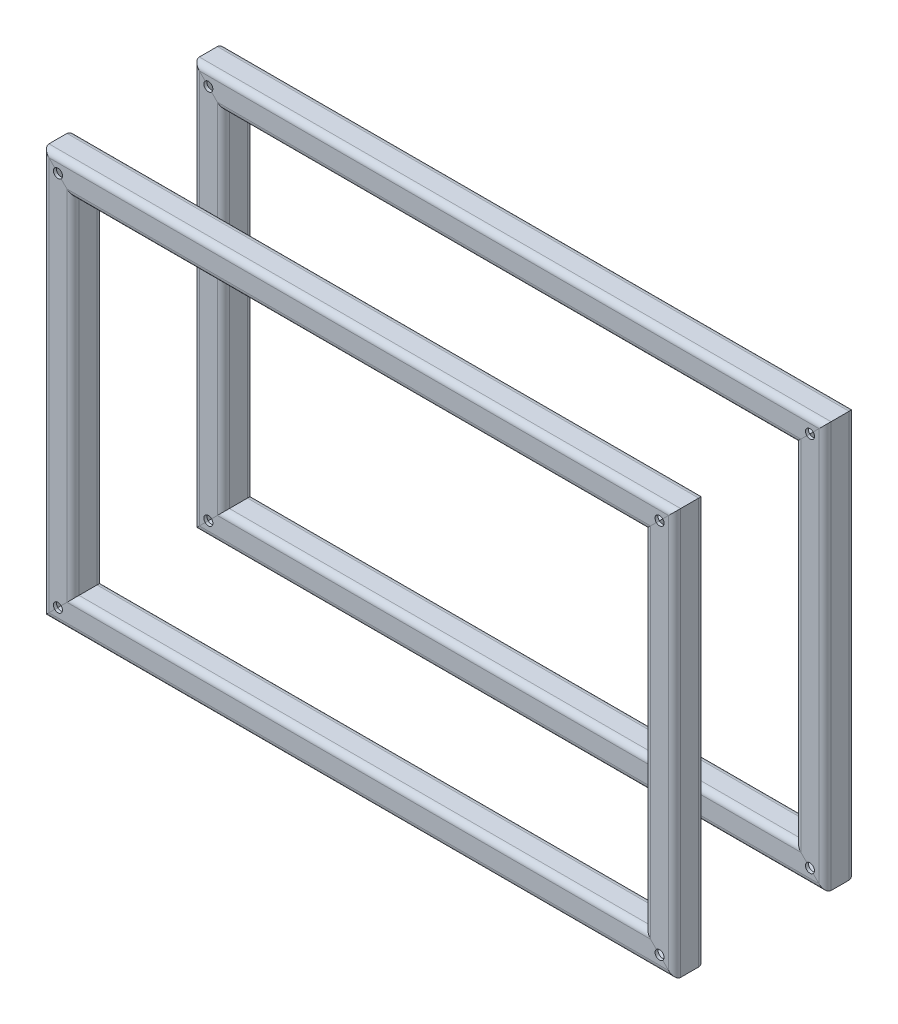
from build123d import *

# Parameters (mm, degrees)
KARE_T_P_20_X_20_X_2_1_DEPTH      = 415.142135624
KARE_T_P_20_X_20_X_2_1_DEPTH_BACK = 15.142135624
KARE_T_P_20_X_20_X_2_1_2_DEPTH    = 280.284271247
KARE_T_P_20_X_20_X_2_1_3_DEPTH    = 430.284271247
KARE_T_P_20_X_20_X_2_1_4_DEPTH    = 280.284271247
IZIM1_R                           = 3
KES_EKSTR_ZYON1_DEPTH             = 277.992779689
KES_EKSTR_ZYON1_DEPTH_BACK        = 277.992779689


with BuildPart() as part:
    # Sketch1 → Kare tüp 20 X 20 X 2(1) (new, two sides)
    with BuildSketch(Plane(origin=(-200, 125, 0), x_dir=(0, 0, -1), z_dir=(1, 0, 0))) as kare_t_p_20_x_20_x_2_1_sk:
        with BuildLine():
            Line((-6, -10), (6, -10))
            ThreePointArc((6, -10), (8.828427125, -8.828427125), (10, -6))
            Line((10, -6), (10, 6))
            ThreePointArc((10, 6), (8.828427125, 8.828427125), (6, 10))
            Line((6, 10), (-6, 10))
            ThreePointArc((-6, 10), (-8.828427125, 8.828427125), (-10, 6))
            Line((-10, 6), (-10, -6))
            ThreePointArc((-10, -6), (-8.828427125, -8.828427125), (-6, -10))
        make_face()
        with BuildLine():
            Line((-6, -8), (6, -8))
            ThreePointArc((6, -8), (7.414213562, -7.414213562), (8, -6))
            Line((8, -6), (8, 6))
            ThreePointArc((8, 6), (7.414213562, 7.414213562), (6, 8))
            Line((6, 8), (-6, 8))
            ThreePointArc((-6, 8), (-7.414213562, 7.414213562), (-8, 6))
            Line((-8, 6), (-8, -6))
            ThreePointArc((-8, -6), (-7.414213562, -7.414213562), (-6, -8))
        make_face(mode=Mode.SUBTRACT)
    extrude(amount=KARE_T_P_20_X_20_X_2_1_DEPTH)
    extrude(kare_t_p_20_x_20_x_2_1_sk.sketch, amount=-KARE_T_P_20_X_20_X_2_1_DEPTH_BACK)

    # Kare tüp 20 X 20 X 2(1) mitre 1
    split(bisect_by=Plane(origin=(-200, 125, 0), x_dir=(-0.707106781, 0.707106781, 0), z_dir=(0.707106781, 0.707106781, 0)), keep=Keep.TOP)

    # Kare tüp 20 X 20 X 2(1) mitre 2
    split(bisect_by=Plane(origin=(200, 125, 0), x_dir=(-0.707106781, -0.707106781, 0), z_dir=(-0.707106781, 0.707106781, 0)), keep=Keep.TOP)


with BuildPart() as body_2:
    # Sketch1 on segment 2 (carried to segment 2) → Kare t_p 20 X 20 X 2_1 2 (new body)
    with BuildSketch(Plane(origin=(200, 140.142135624, 0), x_dir=(0, 0, -1), z_dir=(0, -1, 0))):
        with BuildLine():
            Line((-6, -10), (6, -10))
            ThreePointArc((6, -10), (8.828427125, -8.828427125), (10, -6))
            Line((10, -6), (10, 6))
            ThreePointArc((10, 6), (8.828427125, 8.828427125), (6, 10))
            Line((6, 10), (-6, 10))
            ThreePointArc((-6, 10), (-8.828427125, 8.828427125), (-10, 6))
            Line((-10, 6), (-10, -6))
            ThreePointArc((-10, -6), (-8.828427125, -8.828427125), (-6, -10))
        make_face()
        with BuildLine():
            Line((-6, -8), (6, -8))
            ThreePointArc((6, -8), (7.414213562, -7.414213562), (8, -6))
            Line((8, -6), (8, 6))
            ThreePointArc((8, 6), (7.414213562, 7.414213562), (6, 8))
            Line((6, 8), (-6, 8))
            ThreePointArc((-6, 8), (-7.414213562, 7.414213562), (-8, 6))
            Line((-8, 6), (-8, -6))
            ThreePointArc((-8, -6), (-7.414213562, -7.414213562), (-6, -8))
        make_face(mode=Mode.SUBTRACT)
    extrude(amount=KARE_T_P_20_X_20_X_2_1_2_DEPTH)

    # Kare t_p 20 X 20 X 2_1 2 mitre 1
    split(bisect_by=Plane(origin=(200, 125, 0), x_dir=(0.707106781, 0.707106781, 0), z_dir=(0.707106781, -0.707106781, 0)), keep=Keep.TOP)

    # Kare t_p 20 X 20 X 2_1 2 mitre 2
    split(bisect_by=Plane(origin=(200, -125, 0), x_dir=(-0.707106781, 0.707106781, 0), z_dir=(0.707106781, 0.707106781, 0)), keep=Keep.TOP)


with BuildPart() as body_3:
    # Sketch1 on segment 3 (carried to segment 3) → Kare t_p 20 X 20 X 2_1 3 (new body)
    with BuildSketch(Plane(origin=(215.142135624, -125, 0), x_dir=(0, 0, -1), z_dir=(-1, 0, 0))):
        with BuildLine():
            Line((-6, -10), (6, -10))
            ThreePointArc((6, -10), (8.828427125, -8.828427125), (10, -6))
            Line((10, -6), (10, 6))
            ThreePointArc((10, 6), (8.828427125, 8.828427125), (6, 10))
            Line((6, 10), (-6, 10))
            ThreePointArc((-6, 10), (-8.828427125, 8.828427125), (-10, 6))
            Line((-10, 6), (-10, -6))
            ThreePointArc((-10, -6), (-8.828427125, -8.828427125), (-6, -10))
        make_face()
        with BuildLine():
            Line((-6, -8), (6, -8))
            ThreePointArc((6, -8), (7.414213562, -7.414213562), (8, -6))
            Line((8, -6), (8, 6))
            ThreePointArc((8, 6), (7.414213562, 7.414213562), (6, 8))
            Line((6, 8), (-6, 8))
            ThreePointArc((-6, 8), (-7.414213562, 7.414213562), (-8, 6))
            Line((-8, 6), (-8, -6))
            ThreePointArc((-8, -6), (-7.414213562, -7.414213562), (-6, -8))
        make_face(mode=Mode.SUBTRACT)
    extrude(amount=KARE_T_P_20_X_20_X_2_1_3_DEPTH)

    # Kare t_p 20 X 20 X 2_1 3 mitre 1
    split(bisect_by=Plane(origin=(-200, -125, 0), x_dir=(0.707106781, 0.707106781, 0), z_dir=(0.707106781, -0.707106781, 0)), keep=Keep.TOP)

    # Kare t_p 20 X 20 X 2_1 3 mitre 2
    split(bisect_by=Plane(origin=(200, -125, 0), x_dir=(0.707106781, -0.707106781, 0), z_dir=(-0.707106781, -0.707106781, 0)), keep=Keep.TOP)


with BuildPart() as body_4:
    # Sketch1 on segment 4 (carried to segment 4) → Kare t_p 20 X 20 X 2_1 4 (new body)
    with BuildSketch(Plane(origin=(-200, -140.142135624, 0), x_dir=(0, 0, -1), z_dir=(0, 1, 0))):
        with BuildLine():
            Line((-6, -10), (6, -10))
            ThreePointArc((6, -10), (8.828427125, -8.828427125), (10, -6))
            Line((10, -6), (10, 6))
            ThreePointArc((10, 6), (8.828427125, 8.828427125), (6, 10))
            Line((6, 10), (-6, 10))
            ThreePointArc((-6, 10), (-8.828427125, 8.828427125), (-10, 6))
            Line((-10, 6), (-10, -6))
            ThreePointArc((-10, -6), (-8.828427125, -8.828427125), (-6, -10))
        make_face()
        with BuildLine():
            Line((-6, -8), (6, -8))
            ThreePointArc((6, -8), (7.414213562, -7.414213562), (8, -6))
            Line((8, -6), (8, 6))
            ThreePointArc((8, 6), (7.414213562, 7.414213562), (6, 8))
            Line((6, 8), (-6, 8))
            ThreePointArc((-6, 8), (-7.414213562, 7.414213562), (-8, 6))
            Line((-8, 6), (-8, -6))
            ThreePointArc((-8, -6), (-7.414213562, -7.414213562), (-6, -8))
        make_face(mode=Mode.SUBTRACT)
    extrude(amount=KARE_T_P_20_X_20_X_2_1_4_DEPTH)

    # Kare t_p 20 X 20 X 2_1 4 mitre 1
    split(bisect_by=Plane(origin=(-200, 125, 0), x_dir=(0.707106781, -0.707106781, 0), z_dir=(-0.707106781, -0.707106781, 0)), keep=Keep.TOP)

    # Kare t_p 20 X 20 X 2_1 4 mitre 2
    split(bisect_by=Plane(origin=(-200, -125, 0), x_dir=(-0.707106781, -0.707106781, 0), z_dir=(-0.707106781, 0.707106781, 0)), keep=Keep.TOP)


with BuildPart() as body_5:
    # Aynalama2: mirrored copy
    add(part.part.mirror(Plane.XY.offset(50)))


with BuildPart() as body_6:
    # Aynalama2 2: mirrored copy
    add(body_2.part.mirror(Plane.XY.offset(50)))


with BuildPart() as body_7:
    # Aynalama2 3: mirrored copy
    add(body_3.part.mirror(Plane.XY.offset(50)))


with BuildPart() as body_8:
    # Aynalama2 4: mirrored copy
    add(body_4.part.mirror(Plane.XY.offset(50)))


with BuildPart() as kes_ekstr_zyon1_tool:
    # Çizim1 → Kes-Ekstrüzyon1 (new, two sides)
    with BuildSketch(Plane.XY.offset(110)) as kes_ekstr_zyon1_sk:
        with Locations((-200, 125)):
            Circle(IZIM1_R)
        with Locations((200, 125)):
            Circle(IZIM1_R)
        with Locations((200, -125)):
            Circle(IZIM1_R)
        with Locations((-200, -125)):
            Circle(IZIM1_R)
    extrude(amount=KES_EKSTR_ZYON1_DEPTH)
    extrude(kes_ekstr_zyon1_sk.sketch, amount=-KES_EKSTR_ZYON1_DEPTH_BACK)


with BuildPart() as part_1:
    add(part.part)

    # Kes-Ekstrüzyon1: cut by kes_ekstr_zyon1_tool
    add(kes_ekstr_zyon1_tool.part, mode=Mode.SUBTRACT)


with BuildPart() as body_2_1:
    add(body_2.part)

    # Kes-Ekstrüzyon1: cut by kes_ekstr_zyon1_tool
    add(kes_ekstr_zyon1_tool.part, mode=Mode.SUBTRACT)


with BuildPart() as body_3_1:
    add(body_3.part)

    # Kes-Ekstrüzyon1: cut by kes_ekstr_zyon1_tool
    add(kes_ekstr_zyon1_tool.part, mode=Mode.SUBTRACT)


with BuildPart() as body_4_1:
    add(body_4.part)

    # Kes-Ekstrüzyon1: cut by kes_ekstr_zyon1_tool
    add(kes_ekstr_zyon1_tool.part, mode=Mode.SUBTRACT)


with BuildPart() as body_5_1:
    add(body_5.part)

    # Kes-Ekstrüzyon1: cut by kes_ekstr_zyon1_tool
    add(kes_ekstr_zyon1_tool.part, mode=Mode.SUBTRACT)


with BuildPart() as body_6_1:
    add(body_6.part)

    # Kes-Ekstrüzyon1: cut by kes_ekstr_zyon1_tool
    add(kes_ekstr_zyon1_tool.part, mode=Mode.SUBTRACT)


with BuildPart() as body_7_1:
    add(body_7.part)

    # Kes-Ekstrüzyon1: cut by kes_ekstr_zyon1_tool
    add(kes_ekstr_zyon1_tool.part, mode=Mode.SUBTRACT)


with BuildPart() as body_8_1:
    add(body_8.part)

    # Kes-Ekstrüzyon1: cut by kes_ekstr_zyon1_tool
    add(kes_ekstr_zyon1_tool.part, mode=Mode.SUBTRACT)


solid = Compound([part_1.part, body_2_1.part, body_3_1.part, body_4_1.part, body_5_1.part, body_6_1.part, body_7_1.part, body_8_1.part])
